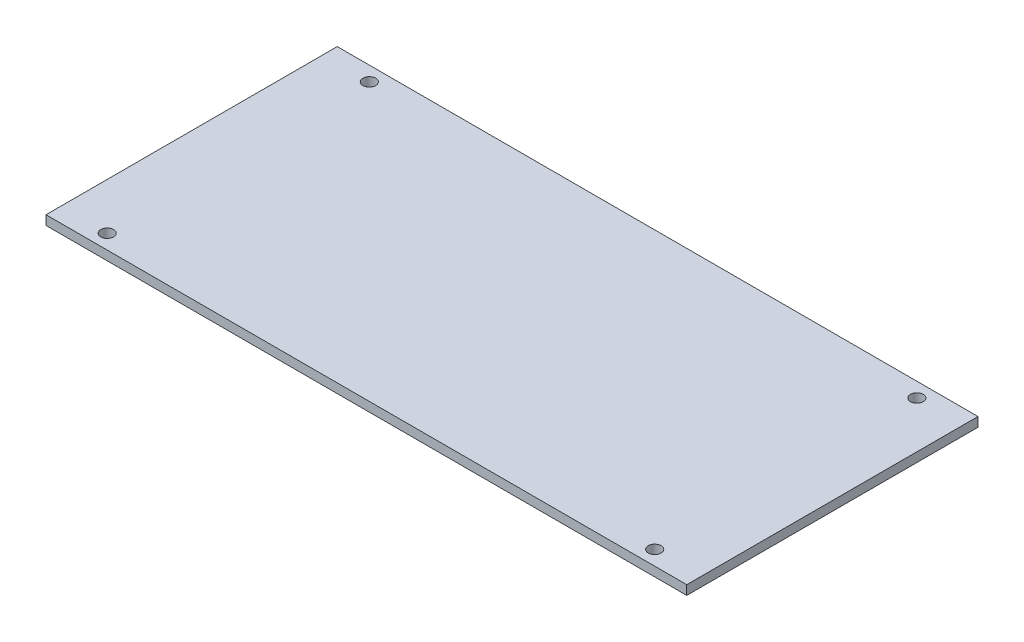
from build123d import *

# Parameters (mm, degrees)
SKETCH1_W           = 139.7
SKETCH1_H           = 63.5
BOSS_EXTRUDE1_DEPTH = 2.032
SKETCH2_R           = 1.397
CUT_EXTRUDE1_DEPTH  = 3.032


with BuildPart() as part:
    # Sketch1 → Boss-Extrude1 (new body)
    with BuildSketch(Plane(origin=(0, 0, 0), x_dir=(1, 0, 0), z_dir=(0, 1, 0))):
        Rectangle(SKETCH1_W, SKETCH1_H)
    extrude(amount=BOSS_EXTRUDE1_DEPTH)

    # Sketch2 → Cut-Extrude1 (cut, through all)
    with BuildSketch(Plane(origin=(0, 2.032, 0), x_dir=(1, 0, 0), z_dir=(0, 1, 0))):
        with Locations((59.69, 28.575)):
            Circle(SKETCH2_R)
        with Locations((-59.69, 28.575)):
            Circle(SKETCH2_R)
        with Locations((59.69, -28.575)):
            Circle(SKETCH2_R)
        with Locations((-59.69, -28.575)):
            Circle(SKETCH2_R)
    extrude(amount=-CUT_EXTRUDE1_DEPTH, mode=Mode.SUBTRACT)


solid = part.part
